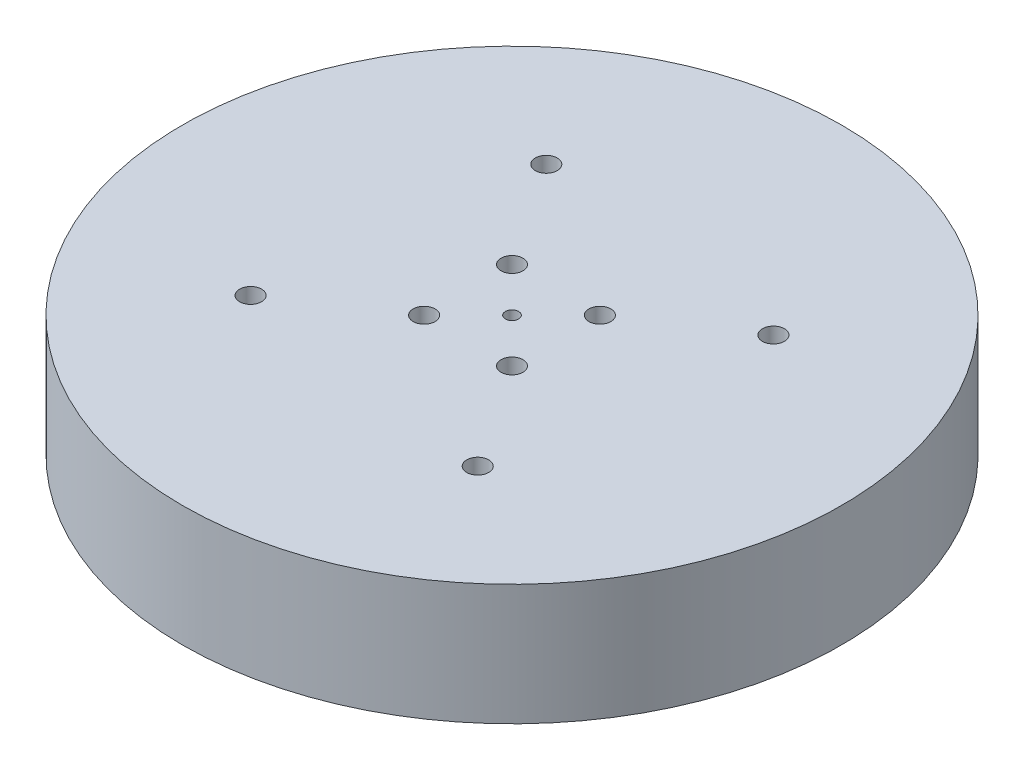
from build123d import *

# Parameters (mm, degrees)
SKETCH1_R            = 75
SKETCH1_R_2          = 70
BOSS_EXTRUDE1_DEPTH  = 22.5
SKETCH2_R            = 75
BOSS_EXTRUDE2_DEPTH  = 5
SKETCH4_R            = 1.5
CUT_EXTRUDE2_DEPTH   = 5
SKETCH5_R            = 2.5
CUT_EXTRUDE3_DEPTH   = 10
LPATTERN1_COUNT      = 2
LPATTERN1_PITCH      = 20
LPATTERN1_COUNT_DIR2 = 2
LPATTERN1_PITCH_DIR2 = 20
SKETCH6_R            = 2.5
CUT_EXTRUDE4_DEPTH   = 10
SKETCH8_R            = 7.5
BOSS_EXTRUDE3_DEPTH  = 7
CUT_EXTRUDE5_DEPTH   = 7


with BuildPart() as part:
    # Sketch1 → Boss-Extrude1 (new body)
    with BuildSketch(Plane(origin=(0, 0, 0), x_dir=(1, 0, 0), z_dir=(0, 1, 0))):
        Circle(SKETCH1_R)
        Circle(SKETCH1_R_2, mode=Mode.SUBTRACT)
    extrude(amount=BOSS_EXTRUDE1_DEPTH)

    # Sketch2 → Boss-Extrude2 (add)
    with BuildSketch(Plane(origin=(0, 22.5, 0), x_dir=(1, 0, 0), z_dir=(0, 1, 0))):
        Circle(SKETCH2_R)
    extrude(amount=BOSS_EXTRUDE2_DEPTH)

    # Sketch4 → Cut-Extrude2 (cut)
    with BuildSketch(Plane(origin=(0, 27.5, 0), x_dir=(1, 0, 0), z_dir=(0, 1, 0))):
        Circle(SKETCH4_R)
    extrude(amount=-CUT_EXTRUDE2_DEPTH, mode=Mode.SUBTRACT)

    # Sketch5 → Cut-Extrude3 (cut)
    with BuildSketch(Plane(origin=(0, 27.5, 0), x_dir=(1, 0, 0), z_dir=(0, 1, 0))):
        with Locations((-10, 10)):
            Circle(SKETCH5_R)
    cut_extrude3 = extrude(amount=-CUT_EXTRUDE3_DEPTH, mode=Mode.SUBTRACT)

    # LPattern1: Cut-Extrude3 2 × 2
    with Locations(*[(j * LPATTERN1_PITCH_DIR2, 0, i * LPATTERN1_PITCH) for i in range(LPATTERN1_COUNT) for j in range(LPATTERN1_COUNT_DIR2) if (i, j) != (0, 0)]):
        add(cut_extrude3, mode=Mode.SUBTRACT)

    # Sketch6 → Cut-Extrude4 (cut)
    with BuildSketch(Plane(origin=(0, 27.5, 0), x_dir=(1, 0, 0), z_dir=(0, 1, 0))):
        with Locations((-25.844790679, 33.64590309)):
            Circle(SKETCH6_R)
        with Locations((33.64590309, 25.844790679)):
            Circle(SKETCH6_R)
        with Locations((-33.64590309, -25.844790679)):
            Circle(SKETCH6_R)
        with Locations((25.844790679, -33.64590309)):
            Circle(SKETCH6_R)
    extrude(amount=-CUT_EXTRUDE4_DEPTH, mode=Mode.SUBTRACT)

    # Sketch8 → Boss-Extrude3 (add)
    with BuildSketch(Plane.XZ.offset(-22.5)):
        with Locations((-33.64590309, 25.844790679)):
            Circle(SKETCH8_R)
        with Locations((25.844790679, 33.64590309)):
            Circle(SKETCH8_R)
        with Locations((33.64590309, -25.844790679)):
            Circle(SKETCH8_R)
        with Locations((-25.844790679, -33.64590309)):
            Circle(SKETCH8_R)
    extrude(amount=BOSS_EXTRUDE3_DEPTH)

    # Sketch7 → Cut-Extrude5 (cut)
    with BuildSketch(Plane.XZ.offset(-22.5)):
        Polygon((-31.336502014, 29.844790679), (-35.955304167, 29.844790679), (-38.264705244, 25.844790679), (-35.955304167, 21.844790679), (-31.336502014, 21.844790679), (-29.027100937, 25.844790679), align=None)
        Polygon((28.154191756, 37.64590309), (23.535389602, 37.64590309), (21.225988525, 33.64590309), (23.535389602, 29.64590309), (28.154191756, 29.64590309), (30.463592832, 33.64590309), align=None)
        Polygon((35.955304167, -21.844790679), (31.336502014, -21.844790679), (29.027100937, -25.844790679), (31.336502014, -29.844790679), (35.955304167, -29.844790679), (38.264705244, -25.844790679), align=None)
        Polygon((-23.535389602, -29.64590309), (-28.154191756, -29.64590309), (-30.463592832, -33.64590309), (-28.154191756, -37.64590309), (-23.535389602, -37.64590309), (-21.225988525, -33.64590309), align=None)
    extrude(amount=CUT_EXTRUDE5_DEPTH, mode=Mode.SUBTRACT)


solid = part.part
